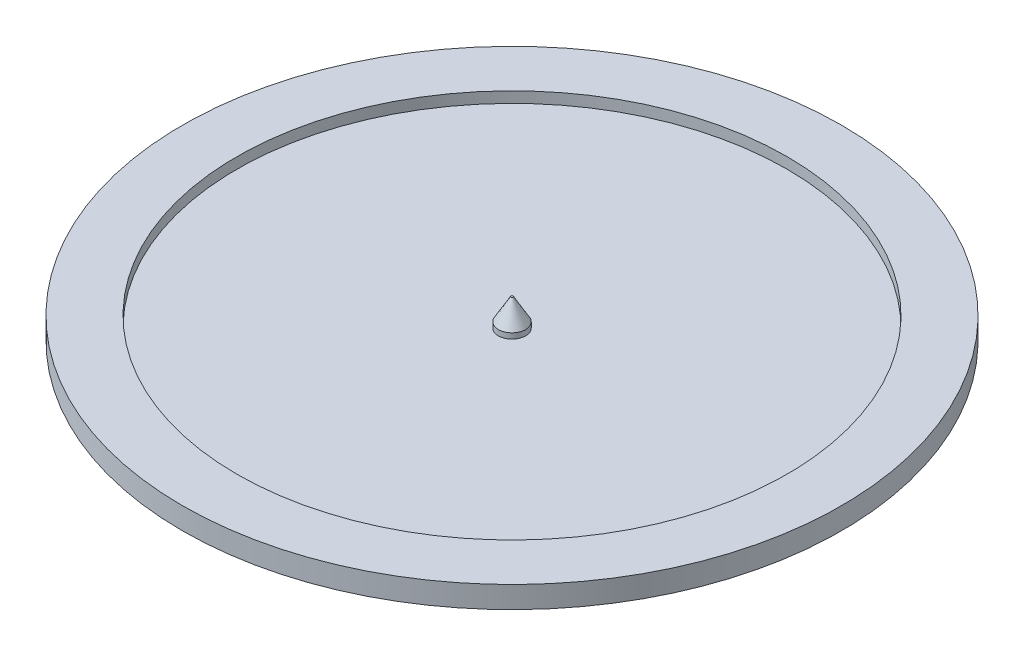
from build123d import *

# Parameters (mm, degrees)
SKETCH1_R           = 60.5
BOSS_EXTRUDE1_DEPTH = 2
SKETCH2_R           = 60.5
SKETCH2_R_2         = 50.5
BOSS_EXTRUDE3_DEPTH = 2
SKETCH3_R           = 2.5
BOSS_EXTRUDE4_DEPTH = 5
CHAMFER1_SIZE       = 4
CHAMFER1_SIZE2      = 2.309401077


with BuildPart() as part:
    # Sketch1 → Boss-Extrude1 (new body)
    with BuildSketch(Plane(origin=(0, 0, 0), x_dir=(1, 0, 0), z_dir=(0, 1, 0))):
        Circle(SKETCH1_R)
    extrude(amount=BOSS_EXTRUDE1_DEPTH)

    # Sketch2 → Boss-Extrude3 (add)
    with BuildSketch(Plane(origin=(0, 2, 0), x_dir=(1, 0, 0), z_dir=(0, 1, 0))):
        Circle(SKETCH2_R)
        Circle(SKETCH2_R_2, mode=Mode.SUBTRACT)
    extrude(amount=BOSS_EXTRUDE3_DEPTH)

    # Sketch3 → Boss-Extrude4 (add)
    with BuildSketch(Plane(origin=(0, 2, 0), x_dir=(1, 0, 0), z_dir=(0, 1, 0))):
        Circle(SKETCH3_R)
    extrude(amount=BOSS_EXTRUDE4_DEPTH)

    # Chamfer1
    chamfer1_edges = [part.edges().sort_by_distance(p)[0] for p in [
        (-2.5, 7, 0),
    ]]
    chamfer1_side = [part.faces().sort_by_distance(p)[0] for p in [
        (-2.5, 4.5, 0),
    ]]
    chamfer(chamfer1_edges, length=CHAMFER1_SIZE, length2=CHAMFER1_SIZE2, reference=chamfer1_side[0])


solid = part.part
